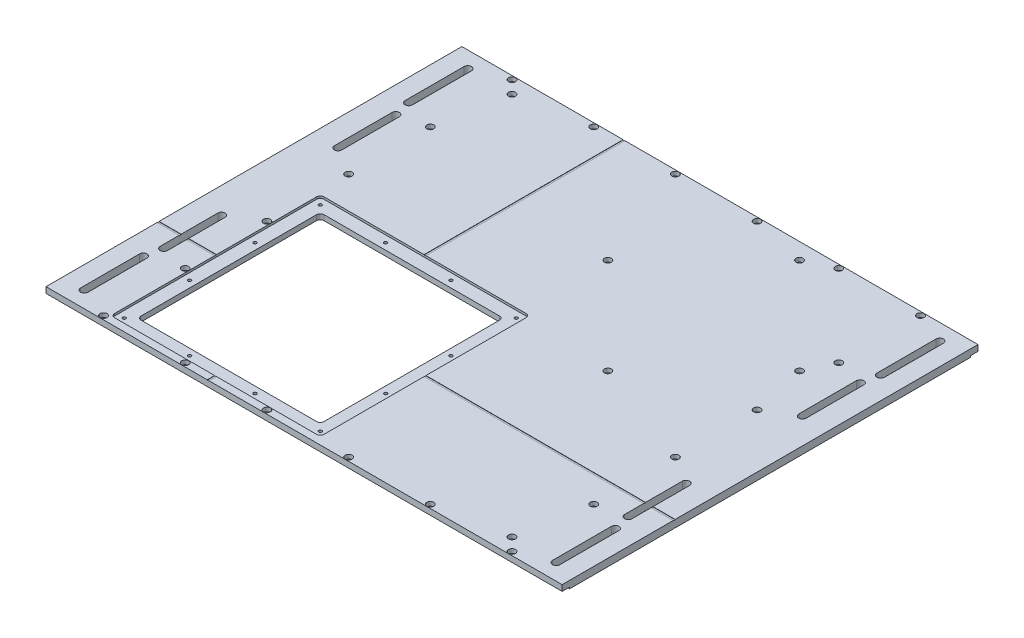
from build123d import *

# Parameters (mm, degrees)
SKETCH1_W                                      = 444.5
SKETCH1_H                                      = 358.14
BOSS_EXTRUDE1_DEPTH                            = 6.35
CUT_EXTRUDE1_DEPTH                             = 6.35
CUT_EXTRUDE2_DEPTH                             = 1.8542
CBORE_FOR_6_SOCKET_HEAD_CAP_SCREW1_D           = 3.6576
CBORE_FOR_6_SOCKET_HEAD_CAP_SCREW1_CBORE_D     = 5.999999938
CBORE_FOR_6_SOCKET_HEAD_CAP_SCREW1_CBORE_DEPTH = 3.5052
CBORE_FOR_6_SOCKET_HEAD_CAP_SCREW2_D           = 3.6576
CBORE_FOR_6_SOCKET_HEAD_CAP_SCREW2_CBORE_D     = 5.999999938
CBORE_FOR_6_SOCKET_HEAD_CAP_SCREW2_CBORE_DEPTH = 3.5052
TAP_DRILL_FOR_6_32_TAP1_D                      = 2.7051
SKETCH21_W                                     = 345.44
SKETCH21_H                                     = 345.44
CUT_EXTRUDE3_DEPTH                             = 1.27
CUT_EXTRUDE4_DEPTH                             = 7.35
CUT_EXTRUDE6_DEPTH                             = 0.254
CUT_EXTRUDE7_DEPTH                             = 0.254


with BuildPart() as part:
    # Sketch1 → Boss-Extrude1 (new body)
    with BuildSketch(Plane(origin=(0, 0, 0), x_dir=(1, 0, 0), z_dir=(0, 1, 0))):
        with Locations((222.25, 179.07)):
            Rectangle(SKETCH1_W, SKETCH1_H)
    extrude(amount=BOSS_EXTRUDE1_DEPTH)

    # Sketch2 → Cut-Extrude1 (cut)
    with BuildSketch(Plane(origin=(0, 6.35, 0), x_dir=(1, 0, 0), z_dir=(0, 1, 0))):
        with BuildLine():
            Line((64.135, 17.78), (215.265, 17.78))
            ThreePointArc((215.265, 17.78), (217.51006403, 18.70993597), (218.44, 20.955))
            Line((218.44, 20.955), (218.44, 172.085))
            ThreePointArc((218.44, 172.085), (217.51006403, 174.33006403), (215.265, 175.26))
            Line((215.265, 175.26), (64.135, 175.26))
            ThreePointArc((64.135, 175.26), (61.88993597, 174.33006403), (60.96, 172.085))
            Line((60.96, 172.085), (60.96, 20.955))
            ThreePointArc((60.96, 20.955), (61.88993597, 18.70993597), (64.135, 17.78))
        make_face()
    extrude(amount=-CUT_EXTRUDE1_DEPTH, mode=Mode.SUBTRACT)

    # Sketch3 → Cut-Extrude2 (cut)
    with BuildSketch(Plane(origin=(0, 6.35, 0), x_dir=(1, 0, 0), z_dir=(0, 1, 0))):
        with BuildLine():
            Line((52.705, 6.35), (226.695, 6.35))
            ThreePointArc((226.695, 6.35), (228.94006403, 7.27993597), (229.87, 9.525))
            Line((229.87, 9.525), (229.87, 183.515))
            ThreePointArc((229.87, 183.515), (228.94006403, 185.76006403), (226.695, 186.69))
            Line((226.695, 186.69), (52.705, 186.69))
            ThreePointArc((52.705, 186.69), (50.45993597, 185.76006403), (49.53, 183.515))
            Line((49.53, 183.515), (49.53, 9.525))
            ThreePointArc((49.53, 9.525), (50.45993597, 7.27993597), (52.705, 6.35))
        make_face()
    extrude(amount=-CUT_EXTRUDE2_DEPTH, mode=Mode.SUBTRACT)

    # CBORE for #6 Socket Head Cap Screw1 (through all)
    with Locations(Plane(origin=(0, 6.35, 0), x_dir=(1, 0, 0), z_dir=(0, 1, 0))):
        with Locations((46.355, 354.965), (116.713, 354.965), (187.071, 354.965), (398.145, 354.965), (327.787, 354.965), (257.429, 354.965), (398.145, 3.175), (327.787, 3.175), (257.429, 3.175), (187.071, 3.175), (116.713, 3.175), (46.355, 3.175), (398.145, 284.607), (398.145, 214.249), (398.145, 143.891), (398.145, 73.533), (46.355, 73.533), (46.355, 143.891), (46.355, 214.249), (46.355, 284.607)):
            CounterBoreHole(CBORE_FOR_6_SOCKET_HEAD_CAP_SCREW1_D / 2, CBORE_FOR_6_SOCKET_HEAD_CAP_SCREW1_CBORE_D / 2, CBORE_FOR_6_SOCKET_HEAD_CAP_SCREW1_CBORE_DEPTH)

    # CBORE for #6 Socket Head Cap Screw2 (through all)
    with Locations(Plane(origin=(249.462488364, 6.35, -88.952448836), x_dir=(0, 0, 1), z_dir=(0, 1, 0))):
        with Locations((-90.117551164, 55.337511636), (-172.667551164, -27.212488364), (-255.217551164, -192.312488364), (74.982448836, 137.887511636), (-172.667551164, 137.887511636), (-255.217551164, 55.337511636)):
            CounterBoreHole(CBORE_FOR_6_SOCKET_HEAD_CAP_SCREW2_D / 2, CBORE_FOR_6_SOCKET_HEAD_CAP_SCREW2_CBORE_D / 2, CBORE_FOR_6_SOCKET_HEAD_CAP_SCREW2_CBORE_DEPTH)

    # Tap Drill for #6-32 Tap1 (through all)
    with Locations(Plane(origin=(249.462488364, 4.4958, -88.952448836), x_dir=(0, 0, 1), z_dir=(0, 1, 0))):
        with Locations((76.815465236, -25.370988364), (20.562948836, -25.370988364), (76.815465236, -81.631988364), (76.815465236, -137.892988364), (76.815465236, -194.153988364), (20.562948836, -194.153988364), (-35.698051164, -194.153988364), (-91.950567564, -194.153988364), (-91.950567564, -137.892988364), (-91.950567564, -81.631988364), (-91.950567564, -25.370988364), (-35.698051164, -25.370988364)):
            Hole(TAP_DRILL_FOR_6_32_TAP1_D / 2)

    # Sketch21 → Cut-Extrude3 (cut)
    with BuildSketch(Plane.XZ):
        Polygon((0, 0), (444.5, 0), (444.5, -6.35), (401.32, -6.35), (401.32, -351.79), (444.5, -351.79), (444.5, -358.14), (0, -358.14), (0, -351.79), (43.18, -351.79), (43.18, -6.35), (0, -6.35), align=None)
        with Locations((222.25, -179.07)):
            Rectangle(SKETCH21_W, SKETCH21_H, mode=Mode.SUBTRACT)
    extrude(amount=-CUT_EXTRUDE3_DEPTH, mode=Mode.SUBTRACT)

    # Sketch22 → Cut-Extrude4 (cut, through all)
    with BuildSketch(Plane.XZ):
        with BuildLine():
            Line((425.425, -79.2415), (425.425, -128.8985))
            ThreePointArc((425.425, -128.8985), (422.25, -132.0735), (419.075, -128.8985))
            Line((419.075, -128.8985), (419.075, -79.2415))
            ThreePointArc((419.075, -79.2415), (422.25, -76.0665), (425.425, -79.2415))
        make_face()
        with BuildLine():
            Line((22.2504, -13.97), (22.2504, -64.77))
            ThreePointArc((22.2504, -64.77), (19.05, -67.9704), (15.8496, -64.77))
            Line((15.8496, -64.77), (15.8496, -13.97))
            ThreePointArc((15.8496, -13.97), (19.05, -10.7696), (22.2504, -13.97))
        make_face()
        with BuildLine():
            Line((22.2504, -344.17), (22.2504, -293.37))
            ThreePointArc((22.2504, -293.37), (19.05, -290.1696), (15.8496, -293.37))
            Line((15.8496, -293.37), (15.8496, -344.17))
            ThreePointArc((15.8496, -344.17), (19.05, -347.3704), (22.2504, -344.17))
        make_face()
        with BuildLine():
            Line((422.2496, -13.97), (422.2496, -64.77))
            ThreePointArc((422.2496, -64.77), (425.45, -67.9704), (428.6504, -64.77))
            Line((428.6504, -64.77), (428.6504, -13.97))
            ThreePointArc((428.6504, -13.97), (425.45, -10.7696), (422.2496, -13.97))
        make_face()
        with BuildLine():
            Line((422.2496, -344.17), (422.2496, -293.37))
            ThreePointArc((422.2496, -293.37), (425.45, -290.1696), (428.6504, -293.37))
            Line((428.6504, -293.37), (428.6504, -344.17))
            ThreePointArc((428.6504, -344.17), (425.45, -347.3704), (422.2496, -344.17))
        make_face()
        with BuildLine():
            Line((425.425, -278.8985), (425.425, -229.2415))
            ThreePointArc((425.425, -229.2415), (422.25, -226.0665), (419.075, -229.2415))
            Line((419.075, -229.2415), (419.075, -278.8985))
            ThreePointArc((419.075, -278.8985), (422.25, -282.0735), (425.425, -278.8985))
        make_face()
        with BuildLine():
            Line((19.075, -79.2415), (19.075, -128.8985))
            ThreePointArc((19.075, -128.8985), (22.25, -132.0735), (25.425, -128.8985))
            Line((25.425, -128.8985), (25.425, -79.2415))
            ThreePointArc((25.425, -79.2415), (22.25, -76.0665), (19.075, -79.2415))
        make_face()
        with BuildLine():
            Line((19.075, -278.8985), (19.075, -229.2415))
            ThreePointArc((19.075, -229.2415), (22.25, -226.0665), (25.425, -229.2415))
            Line((25.425, -229.2415), (25.425, -278.8985))
            ThreePointArc((25.425, -278.8985), (22.25, -282.0735), (19.075, -278.8985))
        make_face()
    extrude(amount=-CUT_EXTRUDE4_DEPTH, mode=Mode.SUBTRACT)

    # Sketch24 → Cut-Extrude6 (cut)
    with BuildSketch(Plane(origin=(0, 6.35, 0), x_dir=(1, 0, 0), z_dir=(0, 1, 0))):
        with BuildLine():
            Line((138.90625, -7.62), (138.90625, 95.72625))
            Line((138.90625, 95.72625), (0, 95.72625))
            ThreePointArc((0, 95.72625), (-0.79375, 96.52), (0, 97.31375))
            Line((0, 97.31375), (138.90625, 97.31375))
            Line((138.90625, 97.31375), (138.90625, 358.14))
            ThreePointArc((138.90625, 358.14), (139.7, 358.93375), (140.49375, 358.14))
            Line((140.49375, 358.14), (140.49375, 97.31375))
            Line((140.49375, 97.31375), (459.74, 97.31375))
            ThreePointArc((459.74, 97.31375), (460.53375, 96.52), (459.74, 95.72625))
            Line((459.74, 95.72625), (140.49375, 95.72625))
            Line((140.49375, 95.72625), (140.49375, -7.62))
            ThreePointArc((140.49375, -7.62), (139.7, -8.41375), (138.90625, -7.62))
        make_face()
    extrude(amount=-CUT_EXTRUDE6_DEPTH, mode=Mode.SUBTRACT)

    # Sketch25 → Cut-Extrude7 (cut)
    with BuildSketch(Plane.XZ):
        with BuildLine():
            Line((-38.1, -95.72625), (38.1, -95.72625))
            ThreePointArc((38.1, -95.72625), (38.89375, -96.52), (38.1, -97.31375))
            Line((38.1, -97.31375), (-38.1, -97.31375))
            ThreePointArc((-38.1, -97.31375), (-38.89375, -96.52), (-38.1, -95.72625))
        make_face()
        with BuildLine():
            Line((482.6, -97.31375), (406.4, -97.31375))
            ThreePointArc((406.4, -97.31375), (405.60625, -96.52), (406.4, -95.72625))
            Line((406.4, -95.72625), (482.6, -95.72625))
            ThreePointArc((482.6, -95.72625), (483.39375, -96.52), (482.6, -97.31375))
        make_face()
    extrude(amount=-CUT_EXTRUDE7_DEPTH, mode=Mode.SUBTRACT)


solid = part.part
